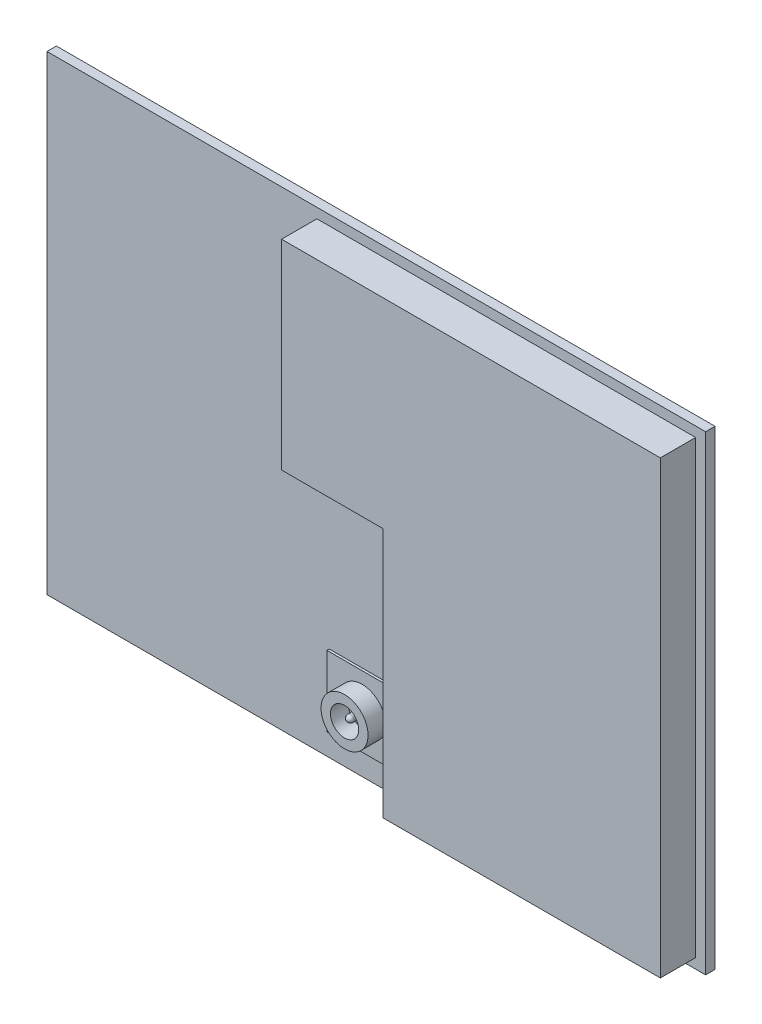
from build123d import *

# Parameters (mm, degrees)
SKETCH1_W           = 28
SKETCH1_H           = 20
BOSS_EXTRUDE1_DEPTH = 0.4
BOSS_EXTRUDE2_DEPTH = 1.5
SKETCH3_W           = 3
SKETCH3_H           = 3
BOSS_EXTRUDE3_DEPTH = 0.1
SKETCH4_R           = 1
SKETCH4_R_2         = 0.6
BOSS_EXTRUDE4_DEPTH = 0.75
SKETCH5_R           = 0.15
BOSS_EXTRUDE5_DEPTH = 0.65
FILLET1_R           = 0.15
SKETCH6_W           = 0.6
SKETCH6_H           = 0.8
SKETCH6_W_2         = 0.8
SKETCH6_H_2         = 0.6
SKETCH6_W_3         = 1
SKETCH6_H_3         = 1
BOSS_EXTRUDE6_DEPTH = 0.1


with BuildPart() as part:
    # Sketch1 → Boss-Extrude1 (new body)
    with BuildSketch(Plane.XY):
        with Locations((14, 10)):
            Rectangle(SKETCH1_W, SKETCH1_H)
    extrude(amount=BOSS_EXTRUDE1_DEPTH)

    # Sketch2 → Boss-Extrude2 (add)
    with BuildSketch(Plane.XY.offset(0.4)):
        Polygon((11.475, 11.075), (15.775, 11.075), (15.775, 0.425), (27.575, 0.425), (27.575, 19.575), (11.475, 19.575), align=None)
    extrude(amount=BOSS_EXTRUDE2_DEPTH)

    # Sketch3 → Boss-Extrude3 (add)
    with BuildSketch(Plane.XY.offset(0.4)):
        with Locations((13.5, 2.5)):
            Rectangle(SKETCH3_W, SKETCH3_H)
    extrude(amount=BOSS_EXTRUDE3_DEPTH)

    # Sketch4 → Boss-Extrude4 (add)
    with BuildSketch(Plane.XY.offset(0.5)):
        with Locations((13.5, 2.5)):
            Circle(SKETCH4_R)
        with Locations((13.5, 2.5)):
            Circle(SKETCH4_R_2, mode=Mode.SUBTRACT)
    extrude(amount=BOSS_EXTRUDE4_DEPTH)

    # Sketch5 → Boss-Extrude5 (add)
    with BuildSketch(Plane.XY.offset(0.5)):
        with Locations((13.5, 2.5)):
            Circle(SKETCH5_R)
    extrude(amount=BOSS_EXTRUDE5_DEPTH)

    # Fillet1
    fillet1_edges = [part.edges().sort_by_distance(p)[0] for p in [
        (13.35, 2.5, 1.15),
    ]]
    fillet(fillet1_edges, radius=FILLET1_R)

    # Sketch6 → Boss-Extrude6 (add)
    with BuildSketch(Plane(origin=(0, 0, 0), x_dir=(-1, 0, 0), z_dir=(0, 0, -1))):
        with Locations((-12.5, 0.7)):
            Rectangle(SKETCH6_W, SKETCH6_H)
        with Locations((-13.5, 0.7)):
            Rectangle(SKETCH6_W, SKETCH6_H)
        with Locations((-14.5, 0.7)):
            Rectangle(SKETCH6_W, SKETCH6_H)
        with Locations((-15.5, 0.7)):
            Rectangle(SKETCH6_W, SKETCH6_H)
        with Locations((-16.5, 0.7)):
            Rectangle(SKETCH6_W, SKETCH6_H)
        with Locations((-17.5, 0.7)):
            Rectangle(SKETCH6_W, SKETCH6_H)
        with Locations((-18.5, 0.7)):
            Rectangle(SKETCH6_W, SKETCH6_H)
        with Locations((-19.5, 0.7)):
            Rectangle(SKETCH6_W, SKETCH6_H)
        with Locations((-20.5, 0.7)):
            Rectangle(SKETCH6_W, SKETCH6_H)
        with Locations((-21.5, 0.7)):
            Rectangle(SKETCH6_W, SKETCH6_H)
        with Locations((-22.5, 0.7)):
            Rectangle(SKETCH6_W, SKETCH6_H)
        with Locations((-23.5, 0.7)):
            Rectangle(SKETCH6_W, SKETCH6_H)
        with Locations((-24.5, 0.7)):
            Rectangle(SKETCH6_W, SKETCH6_H)
        with Locations((-25.5, 0.7)):
            Rectangle(SKETCH6_W, SKETCH6_H)
        with Locations((-26.5, 0.7)):
            Rectangle(SKETCH6_W, SKETCH6_H)
        with Locations((-13.5, 19.3)):
            Rectangle(SKETCH6_W, SKETCH6_H)
        with Locations((-14.5, 19.3)):
            Rectangle(SKETCH6_W, SKETCH6_H)
        with Locations((-15.5, 19.3)):
            Rectangle(SKETCH6_W, SKETCH6_H)
        with Locations((-16.5, 19.3)):
            Rectangle(SKETCH6_W, SKETCH6_H)
        with Locations((-17.5, 19.3)):
            Rectangle(SKETCH6_W, SKETCH6_H)
        with Locations((-18.5, 19.3)):
            Rectangle(SKETCH6_W, SKETCH6_H)
        with Locations((-19.5, 19.3)):
            Rectangle(SKETCH6_W, SKETCH6_H)
        with Locations((-20.5, 19.3)):
            Rectangle(SKETCH6_W, SKETCH6_H)
        with Locations((-21.5, 19.3)):
            Rectangle(SKETCH6_W, SKETCH6_H)
        with Locations((-22.5, 19.3)):
            Rectangle(SKETCH6_W, SKETCH6_H)
        with Locations((-23.5, 19.3)):
            Rectangle(SKETCH6_W, SKETCH6_H)
        with Locations((-24.5, 19.3)):
            Rectangle(SKETCH6_W, SKETCH6_H)
        with Locations((-25.5, 19.3)):
            Rectangle(SKETCH6_W, SKETCH6_H)
        with Locations((-26.5, 19.3)):
            Rectangle(SKETCH6_W, SKETCH6_H)
        with Locations((-12.5, 19.3)):
            Rectangle(SKETCH6_W, SKETCH6_H)
        with Locations((-27.3, 2)):
            Rectangle(SKETCH6_W_2, SKETCH6_H_2)
        with Locations((-11.8, 2)):
            Rectangle(SKETCH6_W_2, SKETCH6_H_2)
        with Locations((-11.8, 3)):
            Rectangle(SKETCH6_W_2, SKETCH6_H_2)
        with Locations((-11.8, 4)):
            Rectangle(SKETCH6_W_2, SKETCH6_H_2)
        with Locations((-11.8, 5)):
            Rectangle(SKETCH6_W_2, SKETCH6_H_2)
        with Locations((-11.8, 6)):
            Rectangle(SKETCH6_W_2, SKETCH6_H_2)
        with Locations((-11.8, 7)):
            Rectangle(SKETCH6_W_2, SKETCH6_H_2)
        with Locations((-11.8, 8)):
            Rectangle(SKETCH6_W_2, SKETCH6_H_2)
        with Locations((-11.8, 9)):
            Rectangle(SKETCH6_W_2, SKETCH6_H_2)
        with Locations((-11.8, 10)):
            Rectangle(SKETCH6_W_2, SKETCH6_H_2)
        with Locations((-11.8, 11)):
            Rectangle(SKETCH6_W_2, SKETCH6_H_2)
        with Locations((-11.8, 12)):
            Rectangle(SKETCH6_W_2, SKETCH6_H_2)
        with Locations((-11.8, 13)):
            Rectangle(SKETCH6_W_2, SKETCH6_H_2)
        with Locations((-11.8, 14)):
            Rectangle(SKETCH6_W_2, SKETCH6_H_2)
        with Locations((-11.8, 15)):
            Rectangle(SKETCH6_W_2, SKETCH6_H_2)
        with Locations((-11.8, 16)):
            Rectangle(SKETCH6_W_2, SKETCH6_H_2)
        with Locations((-11.8, 17)):
            Rectangle(SKETCH6_W_2, SKETCH6_H_2)
        with Locations((-11.8, 18)):
            Rectangle(SKETCH6_W_2, SKETCH6_H_2)
        with Locations((-27.3, 3)):
            Rectangle(SKETCH6_W_2, SKETCH6_H_2)
        with Locations((-27.3, 4)):
            Rectangle(SKETCH6_W_2, SKETCH6_H_2)
        with Locations((-27.3, 5)):
            Rectangle(SKETCH6_W_2, SKETCH6_H_2)
        with Locations((-27.3, 6)):
            Rectangle(SKETCH6_W_2, SKETCH6_H_2)
        with Locations((-27.3, 7)):
            Rectangle(SKETCH6_W_2, SKETCH6_H_2)
        with Locations((-27.3, 8)):
            Rectangle(SKETCH6_W_2, SKETCH6_H_2)
        with Locations((-27.3, 9)):
            Rectangle(SKETCH6_W_2, SKETCH6_H_2)
        with Locations((-27.3, 10)):
            Rectangle(SKETCH6_W_2, SKETCH6_H_2)
        with Locations((-27.3, 11)):
            Rectangle(SKETCH6_W_2, SKETCH6_H_2)
        with Locations((-27.3, 12)):
            Rectangle(SKETCH6_W_2, SKETCH6_H_2)
        with Locations((-27.3, 13)):
            Rectangle(SKETCH6_W_2, SKETCH6_H_2)
        with Locations((-27.3, 14)):
            Rectangle(SKETCH6_W_2, SKETCH6_H_2)
        with Locations((-27.3, 15)):
            Rectangle(SKETCH6_W_2, SKETCH6_H_2)
        with Locations((-27.3, 16)):
            Rectangle(SKETCH6_W_2, SKETCH6_H_2)
        with Locations((-27.3, 17)):
            Rectangle(SKETCH6_W_2, SKETCH6_H_2)
        with Locations((-27.3, 18)):
            Rectangle(SKETCH6_W_2, SKETCH6_H_2)
        with Locations((-19.5, 13.5)):
            Rectangle(SKETCH6_W_3, SKETCH6_H_3)
        with Locations((-16.5, 13.5)):
            Rectangle(SKETCH6_W_3, SKETCH6_H_3)
        with Locations((-22.5, 13.5)):
            Rectangle(SKETCH6_W_3, SKETCH6_H_3)
        with Locations((-19.5, 10)):
            Rectangle(SKETCH6_W_3, SKETCH6_H_3)
        with Locations((-22.5, 10)):
            Rectangle(SKETCH6_W_3, SKETCH6_H_3)
        with Locations((-19.5, 6.5)):
            Rectangle(SKETCH6_W_3, SKETCH6_H_3)
        with Locations((-22.5, 6.5)):
            Rectangle(SKETCH6_W_3, SKETCH6_H_3)
        with Locations((-16.5, 10)):
            Rectangle(SKETCH6_W_3, SKETCH6_H_3)
        with Locations((-16.5, 6.5)):
            Rectangle(SKETCH6_W_3, SKETCH6_H_3)
        with Locations((-0.88, 19.12)):
            Rectangle(SKETCH6_W_3, SKETCH6_H_3)
        with Locations((-0.88, 0.88)):
            Rectangle(SKETCH6_W_3, SKETCH6_H_3)
    extrude(amount=BOSS_EXTRUDE6_DEPTH)


solid = part.part
